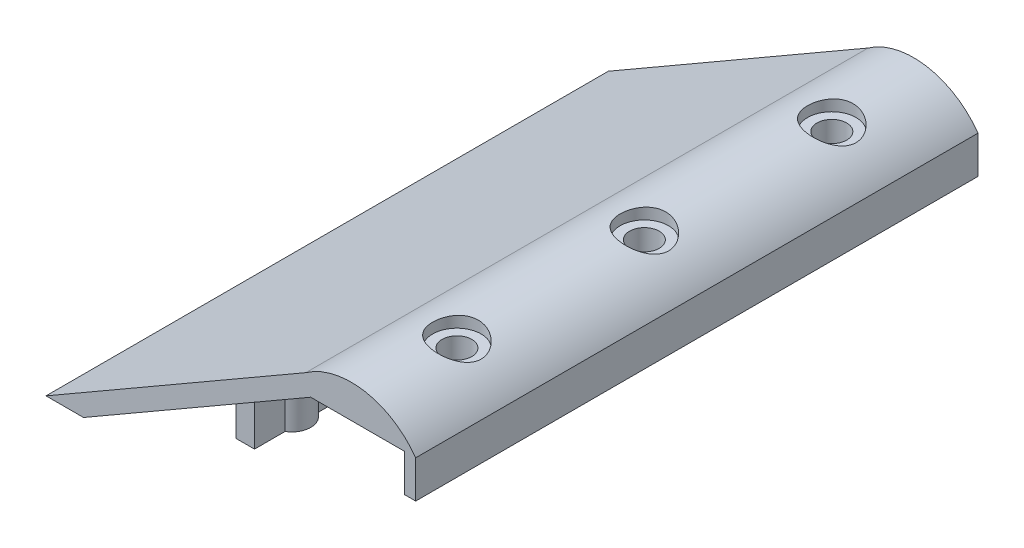
from build123d import *

# Parameters (mm, degrees)
SALIENTE_EXTRUIR1_DEPTH = 75
SALIENTE_EXTRUIR2_START = -17
SALIENTE_EXTRUIR2_DEPTH = 17.566243
CROQUIS3_R              = 3.96875
CORTAR_EXTRUIR1_DEPTH   = 10
CROQUIS4_R              = 6.46875
CROQUIS4_R_2            = 3.96875
CORTAR_EXTRUIR2_DEPTH   = 3
SALIENTE_EXTRUIR3_START = -6.919182
CROQUIS7_R              = 1.984375
SALIENTE_EXTRUIR3_DEPTH = 6.919182
CORTAR_EXTRUIR3_DEPTH   = 75
CROQUIS9_R              = 1
CORTAR_EXTRUIR4_DEPTH   = 10


with BuildPart() as part:
    # Croquis1 → Saliente-Extruir1 (new body, symmetric)
    with BuildSketch(Plane.XY):
        with BuildLine():
            ThreePointArc((-1.339746, 5), (14.365661, 8.57646), (28, 0))
            Line((28, 0), (28, -10))
            Line((28, -10), (25, -10))
            Line((25, -10), (25, 0))
            Line((25, 0), (0, 0))
            Line((0, 0), (-60.621778, -35))
            Line((-60.621778, -35), (-70.621778, -35))
            Line((-70.621778, -35), (-1.339746, 5))
        make_face()
    extrude(amount=SALIENTE_EXTRUIR1_DEPTH, both=True)

    # Croquis2 → Saliente-Extruir2 (add)
    with BuildSketch(Plane(origin=(0, -15, 0), x_dir=(1, 0, 0), z_dir=(0, 1, 0)).offset(SALIENTE_EXTRUIR2_START)):
        with BuildLine():
            Line((-32.5, 4.330127), (-32.5, 12.5))
            Line((-32.5, 12.5), (-27.5, 12.5))
            Line((-27.5, 12.5), (-27.5, 4.330127))
            ThreePointArc((-27.5, 4.330127), (-25, 0), (-27.5, -4.330127))
            Line((-27.5, -4.330127), (-27.5, -12.5))
            Line((-27.5, -12.5), (-32.5, -12.5))
            Line((-32.5, -12.5), (-32.5, -4.330127))
            ThreePointArc((-32.5, -4.330127), (-35, 0), (-32.5, 4.330127))
        make_face()
        with BuildLine():
            Line((-32.5, 54.330127), (-32.5, 62.5))
            Line((-32.5, 62.5), (-27.5, 62.5))
            Line((-27.5, 62.5), (-27.5, 54.330127))
            ThreePointArc((-27.5, 54.330127), (-25, 50), (-27.5, 45.669873))
            Line((-27.5, 45.669873), (-27.5, 37.5))
            Line((-27.5, 37.5), (-32.5, 37.5))
            Line((-32.5, 37.5), (-32.5, 45.669873))
            ThreePointArc((-32.5, 45.669873), (-35, 50), (-32.5, 54.330127))
        make_face()
        with BuildLine():
            Line((-32.5, -45.669873), (-32.5, -37.5))
            Line((-32.5, -37.5), (-27.5, -37.5))
            Line((-27.5, -37.5), (-27.5, -45.669873))
            ThreePointArc((-27.5, -45.669873), (-25, -50), (-27.5, -54.330127))
            Line((-27.5, -54.330127), (-27.5, -62.5))
            Line((-27.5, -62.5), (-32.5, -62.5))
            Line((-32.5, -62.5), (-32.5, -54.330127))
            ThreePointArc((-32.5, -54.330127), (-35, -50), (-32.5, -45.669873))
        make_face()
    extrude(amount=SALIENTE_EXTRUIR2_DEPTH)

    # Croquis3 → Cortar-Extruir1 (cut)
    with BuildSketch(Plane(origin=(0, 8.875562, 0), x_dir=(1, 0, 0), z_dir=(0, 1, 0))):
        with Locations((14, -50)):
            Circle(CROQUIS3_R)
        with Locations((14, 0)):
            Circle(CROQUIS3_R)
        with Locations((14, 50)):
            Circle(CROQUIS3_R)
    extrude(amount=-CORTAR_EXTRUIR1_DEPTH, mode=Mode.SUBTRACT)

    # Croquis4 → Cortar-Extruir2 (cut)
    with BuildSketch(Plane(origin=(0, 8.875562, 0), x_dir=(1, 0, 0), z_dir=(0, 1, 0))):
        with Locations((14, 50)):
            Circle(CROQUIS4_R)
        with Locations((14, 50)):
            Circle(CROQUIS4_R_2, mode=Mode.SUBTRACT)
        with Locations((14, 0)):
            Circle(CROQUIS4_R)
        with Locations((14, 0)):
            Circle(CROQUIS4_R_2, mode=Mode.SUBTRACT)
        with Locations((14, -50)):
            Circle(CROQUIS4_R)
        with Locations((14, -50)):
            Circle(CROQUIS4_R_2, mode=Mode.SUBTRACT)
    extrude(amount=-CORTAR_EXTRUIR2_DEPTH, mode=Mode.SUBTRACT)

    # Croquis7 → Saliente-Extruir3 (add)
    with BuildSketch(Plane(origin=(0, -35, 0), x_dir=(-1, 0, 0), z_dir=(0, -1, 0)).offset(SALIENTE_EXTRUIR3_START)):
        with Locations((50.621778, 0)):
            Circle(CROQUIS7_R)
        with Locations((50.621778, 50)):
            Circle(CROQUIS7_R)
        with Locations((50.621778, -50)):
            Circle(CROQUIS7_R)
    extrude(amount=SALIENTE_EXTRUIR3_DEPTH)

    # Croquis8 → Cortar-Extruir3 (cut, symmetric)
    with BuildSketch(Plane.XY):
        with BuildLine():
            ThreePointArc((-50.621778, -35), (-51.865537, -34.582808), (-52.606153, -33.5))
            Line((-52.606153, -33.5), (-52.606153, -35))
            Line((-52.606153, -35), (-50.621778, -35))
        make_face()
        with BuildLine():
            ThreePointArc((-48.637403, -33.5), (-49.378019, -34.582808), (-50.621778, -35))
            Line((-50.621778, -35), (-48.637403, -35))
            Line((-48.637403, -35), (-48.637403, -33.5))
        make_face()
    extrude(amount=CORTAR_EXTRUIR3_DEPTH, both=True, mode=Mode.SUBTRACT)

    # Croquis9 → Cortar-Extruir4 (cut)
    with BuildSketch(Plane.XZ.offset(32)):
        with Locations((-30, 0)):
            Circle(CROQUIS9_R)
        with Locations((-30, 50)):
            Circle(CROQUIS9_R)
        with Locations((-30, -50)):
            Circle(CROQUIS9_R)
    extrude(amount=-CORTAR_EXTRUIR4_DEPTH, mode=Mode.SUBTRACT)


solid = part.part
